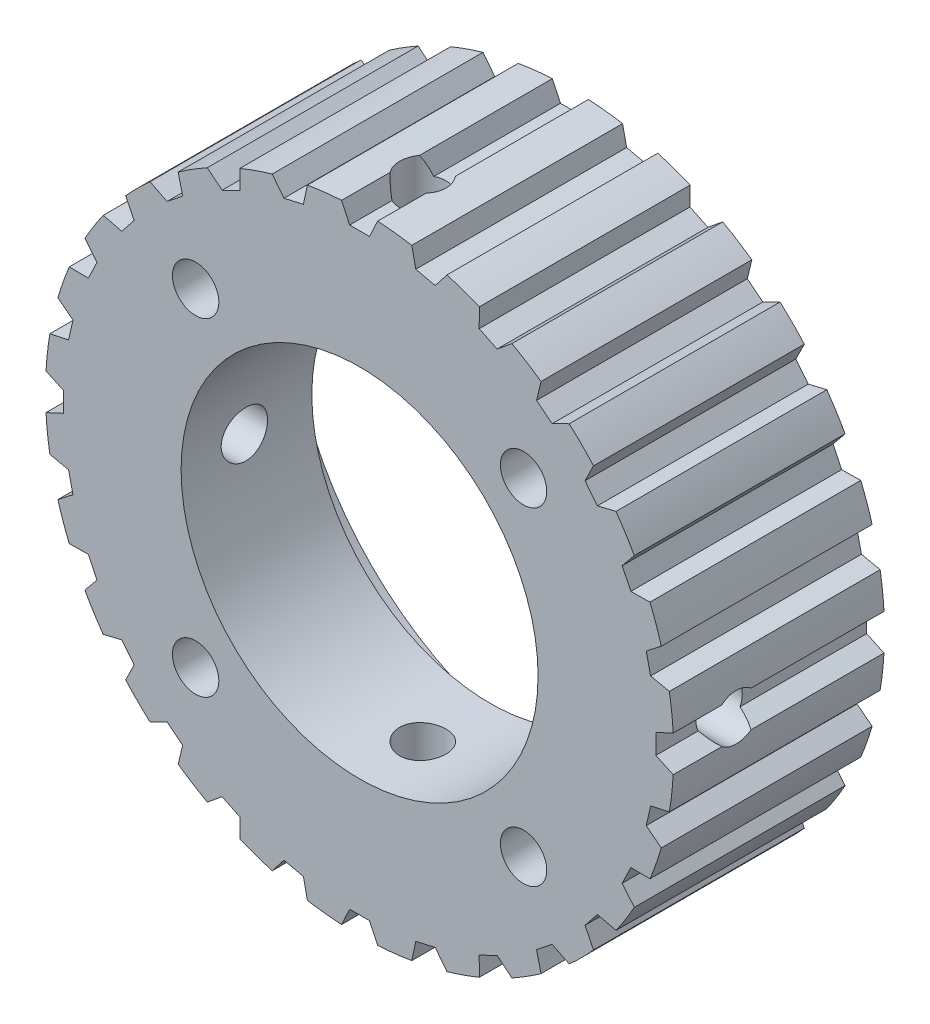
from build123d import *

# Parameters (mm, degrees)
SKETCH1_R               = 22.35
BOSS_EXTRUDE1_DEPTH     = 15
CUT_EXTRUDE1_DEPTH      = 16
SKETCH3_R               = 12.7
CUT_EXTRUDE2_DEPTH      = 16
SKETCH4_R               = 20
CUT_EXTRUDE3_DEPTH      = 5.7
SKETCH5_R               = 1.65
CUT_EXTRUDE4_DEPTH      = 10.3
SKETCH6_R               = 1.65
CUT_EXTRUDE5_DEPTH      = 23.313154774
CUT_EXTRUDE5_DEPTH_BACK = 23.313154774
SKETCH7_R               = 1.65
CUT_EXTRUDE6_DEPTH      = 23.313154774
CUT_EXTRUDE6_DEPTH_BACK = 23.313154774


with BuildPart() as part:
    # Sketch1 → Boss-Extrude1 (new body)
    with BuildSketch(Plane.XY):
        Circle(SKETCH1_R)
    extrude(amount=BOSS_EXTRUDE1_DEPTH)

    # Sketch2 → Cut-Extrude1 (cut, through all)
    with BuildSketch(Plane(origin=(0, 0, 0), x_dir=(-1, 0, 0), z_dir=(0, 0, -1))):
        Polygon((-0.707789274, 21.08), (0.707789274, 21.08), (1.3, 22.35), (-1.3, 22.35), align=None)
        Polygon((4.000697768, 20.708978319), (5.380784807, 20.393982458), (6.24074916, 21.500361623), (3.705936588, 22.078916051), align=None)
        Polygon((8.50857312, 19.299521992), (9.783965322, 18.685325479), (10.868561098, 19.572605337), (8.526042041, 20.700703058), align=None)
        Polygon((12.589793086, 16.922307045), (13.696536961, 16.039708256), (14.951377999, 16.663396891), (12.918616144, 18.284470376), align=None)
        Polygon((16.039708256, 13.696536961), (16.922307045, 12.589793086), (18.284470376, 12.918616144), (16.663396891, 14.951377999), align=None)
        Polygon((18.685325479, 9.783965322), (19.299521992, 8.50857312), (20.700703058, 8.526042041), (19.572605337, 10.868561098), align=None)
        Polygon((20.393982458, 5.380784807), (20.708978319, 4.000697768), (22.078916051, 3.705936588), (21.500361623, 6.24074916), align=None)
        Polygon((21.08, 0.707789274), (21.08, -0.707789274), (22.35, -1.3), (22.35, 1.3), align=None)
        Polygon((20.708978319, -4.000697768), (20.393982458, -5.380784807), (21.500361623, -6.24074916), (22.078916051, -3.705936588), align=None)
        Polygon((19.299521992, -8.50857312), (18.685325479, -9.783965322), (19.572605337, -10.868561098), (20.700703058, -8.526042041), align=None)
        Polygon((16.922307045, -12.589793086), (16.039708256, -13.696536961), (16.663396891, -14.951377999), (18.284470376, -12.918616144), align=None)
        Polygon((13.696536961, -16.039708256), (12.589793086, -16.922307045), (12.918616144, -18.284470376), (14.951377999, -16.663396891), align=None)
        Polygon((9.783965322, -18.685325479), (8.50857312, -19.299521992), (8.526042041, -20.700703058), (10.868561098, -19.572605337), align=None)
        Polygon((5.380784807, -20.393982458), (4.000697768, -20.708978319), (3.705936588, -22.078916051), (6.24074916, -21.500361623), align=None)
        Polygon((0.707789274, -21.08), (-0.707789274, -21.08), (-1.3, -22.35), (1.3, -22.35), align=None)
        Polygon((-4.000697768, -20.708978319), (-5.380784807, -20.393982458), (-6.24074916, -21.500361623), (-3.705936588, -22.078916051), align=None)
        Polygon((-8.50857312, -19.299521992), (-9.783965322, -18.685325479), (-10.868561098, -19.572605337), (-8.526042041, -20.700703058), align=None)
        Polygon((-12.589793086, -16.922307045), (-13.696536961, -16.039708256), (-14.951377999, -16.663396891), (-12.918616144, -18.284470376), align=None)
        Polygon((-16.039708256, -13.696536961), (-16.922307045, -12.589793086), (-18.284470376, -12.918616144), (-16.663396891, -14.951377999), align=None)
        Polygon((-18.685325479, -9.783965322), (-19.299521992, -8.50857312), (-20.700703058, -8.526042041), (-19.572605337, -10.868561098), align=None)
        Polygon((-20.393982458, -5.380784807), (-20.708978319, -4.000697768), (-22.078916051, -3.705936588), (-21.500361623, -6.24074916), align=None)
        Polygon((-21.08, -0.707789274), (-21.08, 0.707789274), (-22.35, 1.3), (-22.35, -1.3), align=None)
        Polygon((-20.708978319, 4.000697768), (-20.393982458, 5.380784807), (-21.500361623, 6.24074916), (-22.078916051, 3.705936588), align=None)
        Polygon((-19.299521992, 8.50857312), (-18.685325479, 9.783965322), (-19.572605337, 10.868561098), (-20.700703058, 8.526042041), align=None)
        Polygon((-16.922307045, 12.589793086), (-16.039708256, 13.696536961), (-16.663396891, 14.951377999), (-18.284470376, 12.918616144), align=None)
        Polygon((-13.696536961, 16.039708256), (-12.589793086, 16.922307045), (-12.918616144, 18.284470376), (-14.951377999, 16.663396891), align=None)
        Polygon((-9.783965322, 18.685325479), (-8.50857312, 19.299521992), (-8.526042041, 20.700703058), (-10.868561098, 19.572605337), align=None)
        Polygon((-5.380784807, 20.393982458), (-4.000697768, 20.708978319), (-3.705936588, 22.078916051), (-6.24074916, 21.500361623), align=None)
    extrude(amount=-CUT_EXTRUDE1_DEPTH, mode=Mode.SUBTRACT)

    # Sketch3 → Cut-Extrude2 (cut, through all)
    with BuildSketch(Plane(origin=(0, 0, 0), x_dir=(-1, 0, 0), z_dir=(0, 0, -1))):
        Circle(SKETCH3_R)
    extrude(amount=-CUT_EXTRUDE2_DEPTH, mode=Mode.SUBTRACT)

    # Sketch4 → Cut-Extrude3 (cut)
    with BuildSketch(Plane(origin=(0, 0, 0), x_dir=(-1, 0, 0), z_dir=(0, 0, -1))):
        Circle(SKETCH4_R)
    extrude(amount=-CUT_EXTRUDE3_DEPTH, mode=Mode.SUBTRACT)

    # Sketch5 → Cut-Extrude4 (cut, through all)
    with BuildSketch(Plane(origin=(0, 0, 5.7), x_dir=(-1, 0, 0), z_dir=(0, 0, -1))):
        with Locations((-11.66726189, 11.66726189)):
            Circle(SKETCH5_R)
        with Locations((11.66726189, 11.66726189)):
            Circle(SKETCH5_R)
        with Locations((11.66726189, -11.66726189)):
            Circle(SKETCH5_R)
        with Locations((-11.66726189, -11.66726189)):
            Circle(SKETCH5_R)
    extrude(amount=-CUT_EXTRUDE4_DEPTH, mode=Mode.SUBTRACT)

    # Sketch6 → Cut-Extrude5 (cut, two sides)
    with BuildSketch(Plane(origin=(0, 0, 0), x_dir=(1, 0, 0), z_dir=(0, 1, 0))) as cut_extrude5_sk:
        with Locations((0, -10.5)):
            Circle(SKETCH6_R)
    extrude(amount=CUT_EXTRUDE5_DEPTH, mode=Mode.SUBTRACT)
    extrude(cut_extrude5_sk.sketch, amount=-CUT_EXTRUDE5_DEPTH_BACK, mode=Mode.SUBTRACT)

    # Sketch7 → Cut-Extrude6 (cut, two sides)
    with BuildSketch(Plane(origin=(0, 0, 0), x_dir=(0, 0, -1), z_dir=(1, 0, 0))) as cut_extrude6_sk:
        with Locations((-10.5, 0)):
            Circle(SKETCH7_R)
    extrude(amount=CUT_EXTRUDE6_DEPTH, mode=Mode.SUBTRACT)
    extrude(cut_extrude6_sk.sketch, amount=-CUT_EXTRUDE6_DEPTH_BACK, mode=Mode.SUBTRACT)


solid = part.part
